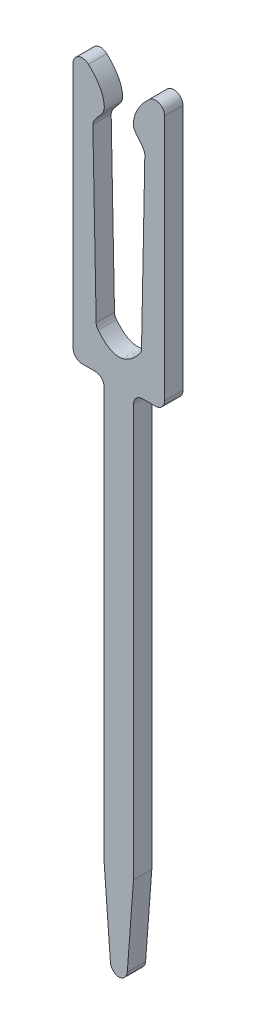
from build123d import *

# Parameters (mm, degrees)
BOSS_EXTRUDE1_DEPTH = 0.2


with BuildPart() as part:
    # Sketch1 → Boss-Extrude1 (new body, symmetric)
    with BuildSketch(Plane.XY):
        with BuildLine():
            Line((-0.32, -7.733224852), (-0.32, 1.266775148))
            ThreePointArc((-0.32, 1.266775148), (-0.378578644, 1.408196504), (-0.52, 1.466775148))
            Line((-0.52, 1.466775148), (-0.8, 1.466775148))
            ThreePointArc((-0.8, 1.466775148), (-0.941421356, 1.525353792), (-1, 1.666775148))
            Line((-1, 1.666775148), (-1, 7.057198685))
            ThreePointArc((-1, 7.057198685), (-0.87939743, 7.240763518), (-0.663039519, 7.202944445))
            add(Edge.make_bspline(
                [(-0.663039519, 7.202944445), (-0.487599251, 7.038079386), (-0.326177604, 6.816155039), (-0.310671132, 6.388247389), (-0.548453888, 6.275984696), (-0.567669208, 6.108344969)],
                knots=[0.253308427, 0.253308427, 0.253308427, 0.253308427, 0.663171976, 0.707067436, 1, 1, 1, 1], degree=3))
            Line((-0.567669208, 6.108344969), (-0.495215905, 2.401684718))
            ThreePointArc((-0.495215905, 2.401684718), (-0.483221967, 2.337269967), (-0.451053839, 2.280188217))
            add(Edge.make_bspline(
                [(-0.451053839, 2.280188217), (0, 1.719811783), (0.451053839, 2.280188217)],
                knots=[0.043404734, 0.043404734, 0.043404734, 0.956595266, 0.956595266, 0.956595266], degree=2))
            ThreePointArc((0.451053839, 2.280188217), (0.483221967, 2.337269967), (0.495215905, 2.401684718))
            Line((0.495215905, 2.401684718), (0.567669208, 6.108344969))
            add(Edge.make_bspline(
                [(0.663039519, 7.202944445), (0.487599251, 7.038079386), (0.326177604, 6.816155039), (0.310671132, 6.388247389), (0.548453888, 6.275984696), (0.567669208, 6.108344969)],
                knots=[0.253308427, 0.253308427, 0.253308427, 0.253308427, 0.663171976, 0.707067436, 1, 1, 1, 1], degree=3))
            ThreePointArc((0.663039519, 7.202944445), (0.87939743, 7.240763518), (1, 7.057198685))
            Line((1, 7.057198685), (1, 1.666775148))
            ThreePointArc((1, 1.666775148), (0.941421356, 1.525353792), (0.8, 1.466775148))
            Line((0.8, 1.466775148), (0.52, 1.466775148))
            ThreePointArc((0.52, 1.466775148), (0.378578644, 1.408196504), (0.32, 1.266775148))
            Line((0.32, 1.266775148), (0.32, -7.733224852))
            Line((0.32, -7.733224852), (0.183878151, -9.548182842))
            ThreePointArc((0.183878151, -9.548182842), (0.126073555, -9.674431974), (0, -9.732618516))
            ThreePointArc((0, -9.732618516), (-0.126073555, -9.674431974), (-0.183878151, -9.548182842))
            Line((-0.183878151, -9.548182842), (-0.32, -7.733224852))
        make_face()
    extrude(amount=BOSS_EXTRUDE1_DEPTH, both=True)


solid = part.part
